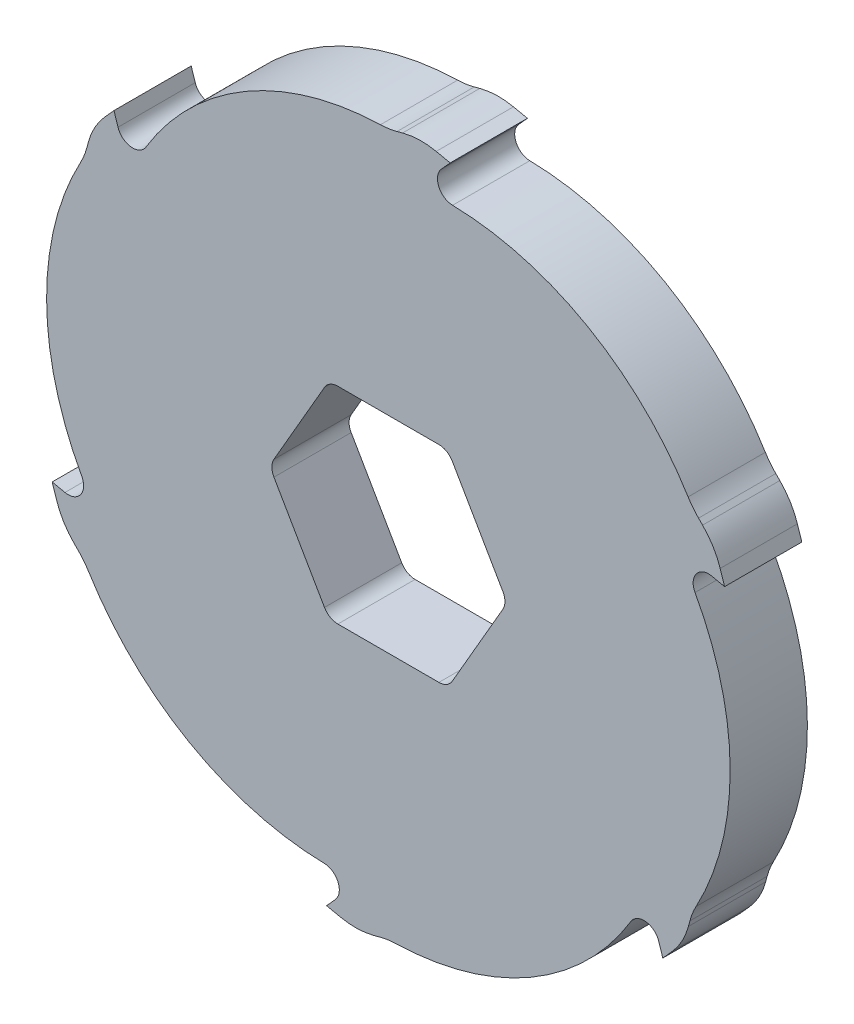
from build123d import *

# Parameters (mm, degrees)
SKETCH1_R               = 70
BOSS_EXTRUDE1_DEPTH     = 7.5
FILLET1_R               = 3
CUT_EXTRUDE2_DEPTH      = 100.278648258
CUT_EXTRUDE2_DEPTH_BACK = 100.278648258
CUT_EXTRUDE3_DEPTH      = 98.628141683
CUT_EXTRUDE3_DEPTH_BACK = 98.628141683
FILLET2_R               = 14
FILLET3_R               = 3


with BuildPart() as part:
    # Sketch1 → Boss-Extrude1 (new, symmetric)
    with BuildSketch(Plane.XY):
        Circle(SKETCH1_R)
        Polygon((23.094010768, 0), (11.547005384, 20), (-11.547005384, 20), (-23.094010768, 0), (-11.547005384, -20), (11.547005384, -20), align=None, mode=Mode.SUBTRACT)
    extrude(amount=BOSS_EXTRUDE1_DEPTH, both=True)

    # Fillet1
    fillet1_edges = [part.edges().sort_by_distance(p)[0] for p in [
        (23.094010768, 0, 0),
        (11.547005384, 20, 0),
        (-11.547005384, 20, 0),
        (-23.094010768, 0, 0),
        (-11.547005384, -20, 0),
        (11.547005384, -20, 0),
    ]]
    fillet(fillet1_edges, radius=FILLET1_R)

    # Sketch3 → Cut-Extrude2 (cut, two sides)
    with BuildSketch(Plane.XY) as cut_extrude2_sk:
        with BuildLine():
            ThreePointArc((63.398675482, 29.675039126), (40.067343971, 57.398675482), (6, 69.742383097))
            Line((6, 69.742383097), (12, 68.467043727))
            Line((12, 68.467043727), (5.525264217, 61.276121136))
            ThreePointArc((5.525264217, 61.276121136), (36.300148732, 55.601545074), (59.006370637, 34.067343971))
            Line((59.006370637, 34.067343971), (63.398675482, 29.675039126))
        make_face()
        with BuildLine():
            ThreePointArc((-50.304045441, 35.423079743), (-30.002276158, 59.2376235), (0, 68.134687942))
            Line((0, 68.134687942), (0, 70))
            ThreePointArc((0, 70), (-32.367313157, 62.067358885), (-57.398675482, 40.067343971))
            Line((-57.398675482, 40.067343971), (-53.294199189, 44.625826709))
            Line((-53.294199189, 44.625826709), (-50.304045441, 35.423079743))
        make_face()
        with BuildLine():
            ThreePointArc((70, 0), (68.329742001, 15.200209147), (63.398675482, 29.675039126))
            Line((63.398675482, 29.675039126), (65.294199189, 23.841217018))
            Line((65.294199189, 23.841217018), (55.829309658, 25.853041393))
            ThreePointArc((55.829309658, 25.853041393), (66.30242489, -3.636078426), (59.006370637, -34.067343971))
            Line((59.006370637, -34.067343971), (57.398675482, -40.067343971))
            ThreePointArc((57.398675482, -40.067343971), (66.77539698, -21.001103736), (70, 0))
        make_face()
        with BuildLine():
            Line((-59.006370637, 34.067343971), (-57.398675482, 40.067343971))
            ThreePointArc((-57.398675482, 40.067343971), (-69.742383097, 6), (-63.398675482, -29.675039126))
            Line((-63.398675482, -29.675039126), (-65.294199189, -23.841217018))
            Line((-65.294199189, -23.841217018), (-55.829309658, -25.853041393))
            ThreePointArc((-55.829309658, -25.853041393), (-66.30242489, 3.636078426), (-59.006370637, 34.067343971))
        make_face()
        with BuildLine():
            Line((-59.006370637, -34.067343971), (-63.398675482, -29.675039126))
            ThreePointArc((-63.398675482, -29.675039126), (-40.067343971, -57.398675482), (-6, -69.742383097))
            Line((-6, -69.742383097), (-12, -68.467043727))
            Line((-12, -68.467043727), (-5.525264217, -61.276121136))
            ThreePointArc((-5.525264217, -61.276121136), (-36.300148732, -55.601545074), (-59.006370637, -34.067343971))
        make_face()
        with BuildLine():
            Line((0, -68.134687942), (-6, -69.742383097))
            ThreePointArc((-6, -69.742383097), (29.675039126, -63.398675482), (57.398675482, -40.067343971))
            Line((57.398675482, -40.067343971), (53.294199189, -44.625826709))
            Line((53.294199189, -44.625826709), (50.304045441, -35.423079743))
            ThreePointArc((50.304045441, -35.423079743), (30.002276158, -59.2376235), (0, -68.134687942))
        make_face()
    extrude(amount=CUT_EXTRUDE2_DEPTH, mode=Mode.SUBTRACT)
    extrude(cut_extrude2_sk.sketch, amount=-CUT_EXTRUDE2_DEPTH_BACK, mode=Mode.SUBTRACT)

    # Sketch4 → Cut-Extrude3 (cut, two sides)
    with BuildSketch(Plane.XY.offset(7.5)) as cut_extrude3_sk:
        Polygon((0, 68.134687942), (6, 69.742383097), (0, 70), align=None)
    extrude(amount=CUT_EXTRUDE3_DEPTH, mode=Mode.SUBTRACT)
    extrude(cut_extrude3_sk.sketch, amount=-CUT_EXTRUDE3_DEPTH_BACK, mode=Mode.SUBTRACT)


with BuildPart() as body_2:
    # of the pieces the cut leaves, the one that is kept (cut_extrude3_keep)
    add(part.part.solids().sort_by_distance((55.829309658, 25.853041393, 7.5))[0])

    # Fillet2
    fillet2_edges = [body_2.edges().sort_by_distance(p)[0] for p in [
        (63.398675482, 29.675039126, 0),
        (-57.398675482, 40.067343971, 0),
        (-59.006370637, -34.067343971, 0),
        (-6, -69.742383097, 0),
        (0, 68.134687942, 0),
        (0, -68.134687942, 0),
        (57.398675482, -40.067343971, 0),
        (-59.006370637, 34.067343971, 0),
        (-63.398675482, -29.675039126, 0),
        (59.006370637, 34.067343971, 0),
        (6, 69.742383097, 0),
        (59.006370637, -34.067343971, 0),
    ]]
    fillet(fillet2_edges, radius=FILLET2_R)

    # Fillet3
    fillet3_edges = [body_2.edges().sort_by_distance(p)[0] for p in [
        (-50.304045441, 35.423079743, 0),
        (-5.525264217, -61.276121136, 0),
        (50.304045441, -35.423079743, 0),
        (-55.829309658, -25.853041393, 0),
        (5.525264217, 61.276121136, 0),
        (55.829309658, 25.853041393, 0),
    ]]
    fillet(fillet3_edges, radius=FILLET3_R)


solid = body_2.part
